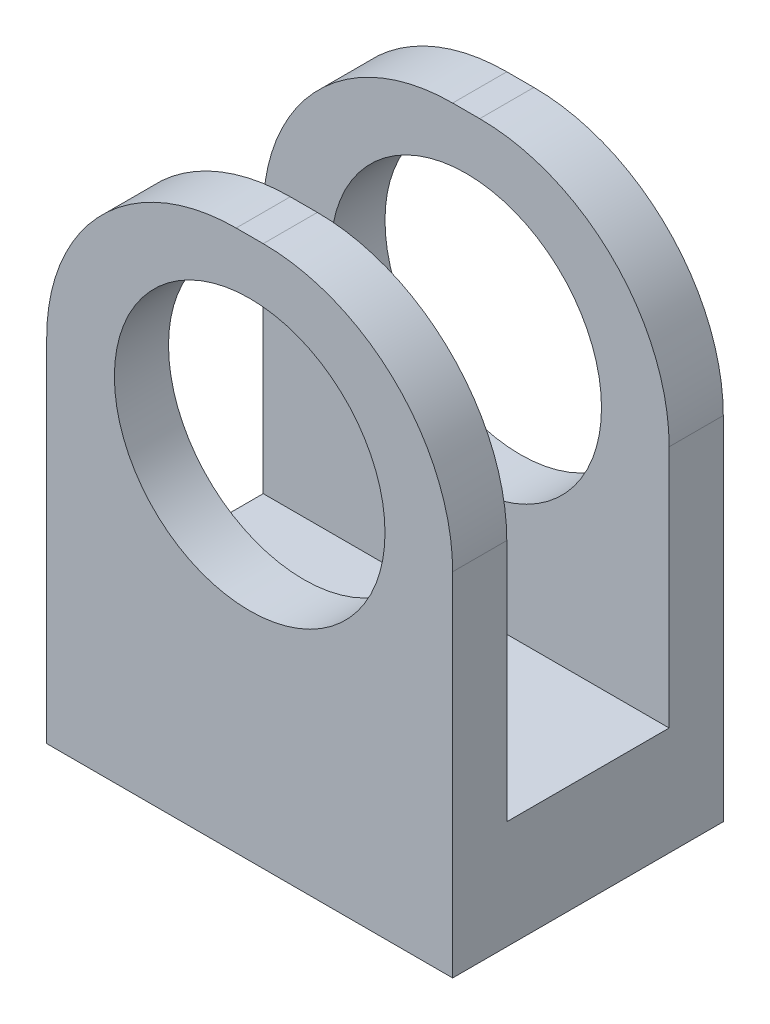
from build123d import *

# Parameters (mm, degrees)
CROQUIS1_R              = 5
SALIENTE_EXTRUIR1_DEPTH = 10
CROQUIS2_W              = 6
CROQUIS2_H              = 16
CORTAR_EXTRUIR1_DEPTH   = 16


with BuildPart() as part:
    # Croquis1 → Saliente-Extruir1 (new body)
    with BuildSketch(Plane.XY):
        with BuildLine():
            Line((-3.852526449, 10.48553719), (-2.852526449, 10.48553719))
            ThreePointArc((-2.852526449, 10.48553719), (2.097221019, 8.435284658), (4.147473551, 3.48553719))
            Line((4.147473551, 3.48553719), (4.147473551, -9.51446281))
            Line((4.147473551, -9.51446281), (-10.852526449, -9.51446281))
            Line((-10.852526449, -9.51446281), (-10.852526449, 3.48553719))
            ThreePointArc((-10.852526449, 3.48553719), (-8.802273917, 8.435284658), (-3.852526449, 10.48553719))
        make_face()
        with Locations((-3.352526449, 3.48553719)):
            Circle(CROQUIS1_R, mode=Mode.SUBTRACT)
    extrude(amount=SALIENTE_EXTRUIR1_DEPTH)

    # Croquis2 → Cortar-Extruir1 (cut, through all)
    with BuildSketch(Plane(origin=(4.147473551, 0, 0), x_dir=(0, 0, -1), z_dir=(1, 0, 0))):
        with Locations((-5, 2.48553719)):
            Rectangle(CROQUIS2_W, CROQUIS2_H)
    extrude(amount=-CORTAR_EXTRUIR1_DEPTH, mode=Mode.SUBTRACT)


solid = part.part
